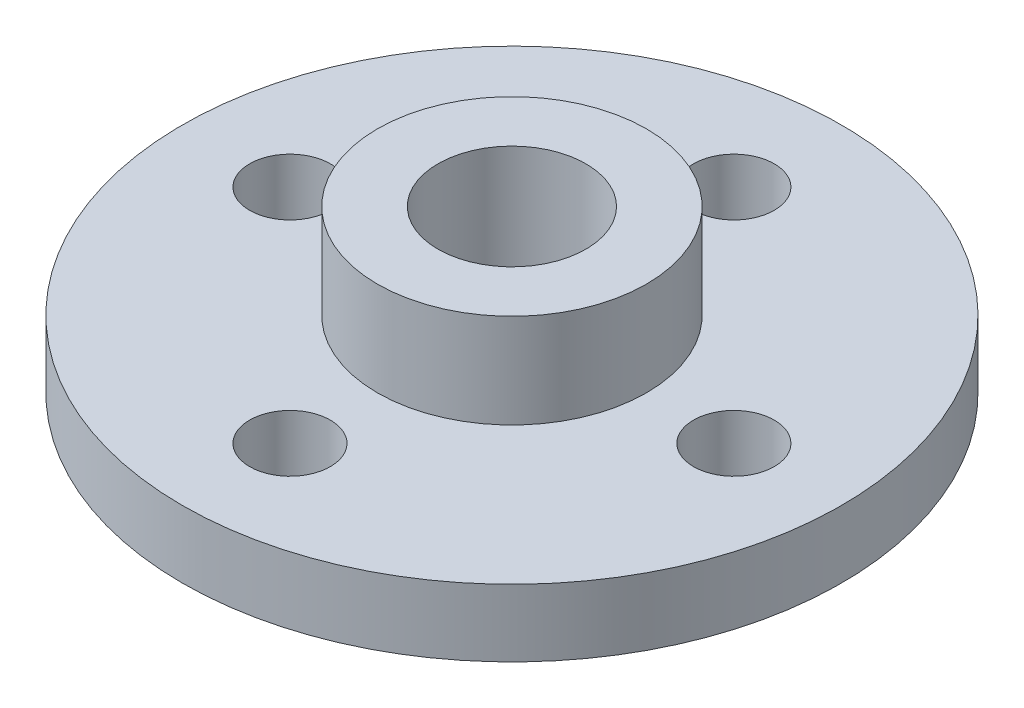
from build123d import *

# Parameters (mm, degrees)
SKETCH_1_R          = 12.25
EXTRUDE_1_DEPTH     = 2.5
SKETCH_1_3_R        = 5
EXTRUDE_2_DEPTH     = 6
SKETCH_2_R          = 1.5
CUT_EXTRUDE_2_DEPTH = 6
CUT_EXTRUDE_START   = 6
SKETCH_2_3_R        = 2.75
CUT_EXTRUDE_3_DEPTH = 4


with BuildPart() as part:
    # Эскиз1 → Бобышка-Вытянуть1 (new body)
    with BuildSketch(Plane(origin=(0, 0, 0), x_dir=(1, 0, 0), z_dir=(0, 1, 0))):
        Circle(SKETCH_1_R)
    extrude(amount=EXTRUDE_1_DEPTH)

    # Эскиз1<3> → Бобышка-Вытянуть2 (add)
    with BuildSketch(Plane(origin=(0, 0, 0), x_dir=(1, 0, 0), z_dir=(0, 1, 0))):
        Circle(SKETCH_1_3_R)
    extrude(amount=EXTRUDE_2_DEPTH)

    # Эскиз2 → Вырез-Вытянуть2 (cut)
    with BuildSketch(Plane(origin=(0, 0, 0), x_dir=(1, 0, 0), z_dir=(0, 1, 0))):
        Circle(SKETCH_2_R)
        with Locations((-8.25, 0)):
            Circle(SKETCH_2_R)
        with Locations((0, 8.25)):
            Circle(SKETCH_2_R)
        with Locations((8.25, 0)):
            Circle(SKETCH_2_R)
        with Locations((0, -8.25)):
            Circle(SKETCH_2_R)
    extrude(amount=CUT_EXTRUDE_2_DEPTH, mode=Mode.SUBTRACT)

    # Эскиз2<3> → Вырез-Вытянуть3 (cut)
    with BuildSketch(Plane(origin=(0, 0, 0), x_dir=(1, 0, 0), z_dir=(0, 1, 0)).offset(CUT_EXTRUDE_START)):
        Circle(SKETCH_2_3_R)
    extrude(amount=-CUT_EXTRUDE_3_DEPTH, mode=Mode.SUBTRACT)


solid = part.part
